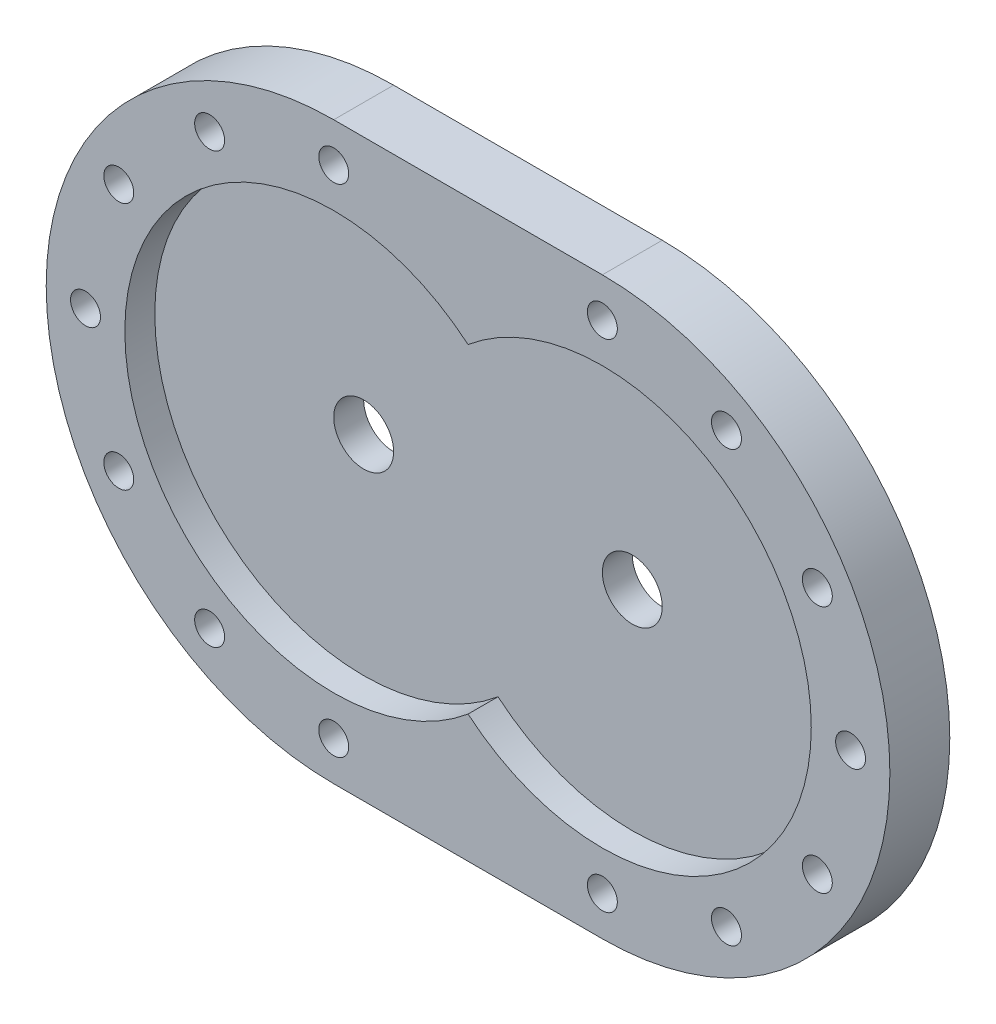
from build123d import *

# Parameters (mm, degrees)
IZIM1_R                     = 5
Y_KSEKLIK_EKSTR_ZYON1_DEPTH = 20
IZIM1_3_R                   = 10
Y_KSEKLIK_EKSTR_ZYON2_DEPTH = 10
Y_KSEKLIK_EKSTR_ZYON3_DEPTH = 20


with BuildPart() as part:
    # Çizim1 → Yükseklik-Ekstrüzyon1 (new body)
    with BuildSketch(Plane.XY):
        with BuildLine():
            ThreePointArc((-44.845, 96), (-140.845, 0), (-44.845, -96))
            ThreePointArc((-44.845, -96), (-21.743660159, -93.179011035), (0, -84.881835365))
            ThreePointArc((0, -84.881835365), (21.743660159, -93.179011035), (44.845, -96))
            ThreePointArc((44.845, -96), (140.845, 0), (44.845, 96))
            ThreePointArc((44.845, 96), (21.743660159, 93.179011035), (0, 84.881835365))
            ThreePointArc((0, 84.881835365), (-21.743660159, 93.179011035), (-44.845, 96))
        make_face()
        with Locations((-86.2825, -71.771855339)):
            Circle(IZIM1_R, mode=Mode.SUBTRACT)
        with Locations((-44.845, -82.875)):
            Circle(IZIM1_R, mode=Mode.SUBTRACT)
        with Locations((-116.616855339, -41.4375)):
            Circle(IZIM1_R, mode=Mode.SUBTRACT)
        with Locations((44.845, -82.875)):
            Circle(IZIM1_R, mode=Mode.SUBTRACT)
        with Locations((86.2825, -71.771855339)):
            Circle(IZIM1_R, mode=Mode.SUBTRACT)
        with Locations((116.616855339, -41.4375)):
            Circle(IZIM1_R, mode=Mode.SUBTRACT)
        with Locations((-127.72, 0)):
            Circle(IZIM1_R, mode=Mode.SUBTRACT)
        with Locations((-116.616855339, 41.4375)):
            Circle(IZIM1_R, mode=Mode.SUBTRACT)
        with Locations((-86.2825, 71.771855339)):
            Circle(IZIM1_R, mode=Mode.SUBTRACT)
        with Locations((-44.845, 82.875)):
            Circle(IZIM1_R, mode=Mode.SUBTRACT)
        with BuildLine():
            ThreePointArc((0, -53.422733691), (-114.595, 0), (0, 53.422733691))
            ThreePointArc((0, 53.422733691), (114.595, 0), (0, -53.422733691))
        make_face(mode=Mode.SUBTRACT)
        with Locations((127.72, 0)):
            Circle(IZIM1_R, mode=Mode.SUBTRACT)
        with Locations((116.616855339, 41.4375)):
            Circle(IZIM1_R, mode=Mode.SUBTRACT)
        with Locations((44.845, 82.875)):
            Circle(IZIM1_R, mode=Mode.SUBTRACT)
        with Locations((86.2825, 71.771855339)):
            Circle(IZIM1_R, mode=Mode.SUBTRACT)
    extrude(amount=Y_KSEKLIK_EKSTR_ZYON1_DEPTH)

    # Çizim1<3> → Yükseklik-Ekstrüzyon2 (add)
    with BuildSketch(Plane.XY):
        with BuildLine():
            ThreePointArc((0, -53.422733691), (114.595, 0), (0, 53.422733691))
            ThreePointArc((0, 53.422733691), (-114.595, 0), (0, -53.422733691))
        make_face()
        with Locations((-44.845, 0)):
            Circle(IZIM1_3_R, mode=Mode.SUBTRACT)
        with Locations((44.845, 0)):
            Circle(IZIM1_3_R, mode=Mode.SUBTRACT)
    extrude(amount=Y_KSEKLIK_EKSTR_ZYON2_DEPTH)

    # Çizim1<5> → Yükseklik-Ekstrüzyon3 (add)
    with BuildSketch(Plane.XY):
        with BuildLine():
            ThreePointArc((0, -84.881835365), (-21.743660159, -93.179011035), (-44.845, -96))
            Line((-44.845, -96), (44.845, -96))
            ThreePointArc((44.845, -96), (21.743660159, -93.179011035), (0, -84.881835365))
        make_face()
        with BuildLine():
            Line((44.845, 96), (-44.845, 96))
            ThreePointArc((-44.845, 96), (-21.743660159, 93.179011035), (0, 84.881835365))
            ThreePointArc((0, 84.881835365), (21.743660159, 93.179011035), (44.845, 96))
        make_face()
    extrude(amount=Y_KSEKLIK_EKSTR_ZYON3_DEPTH)


solid = part.part
